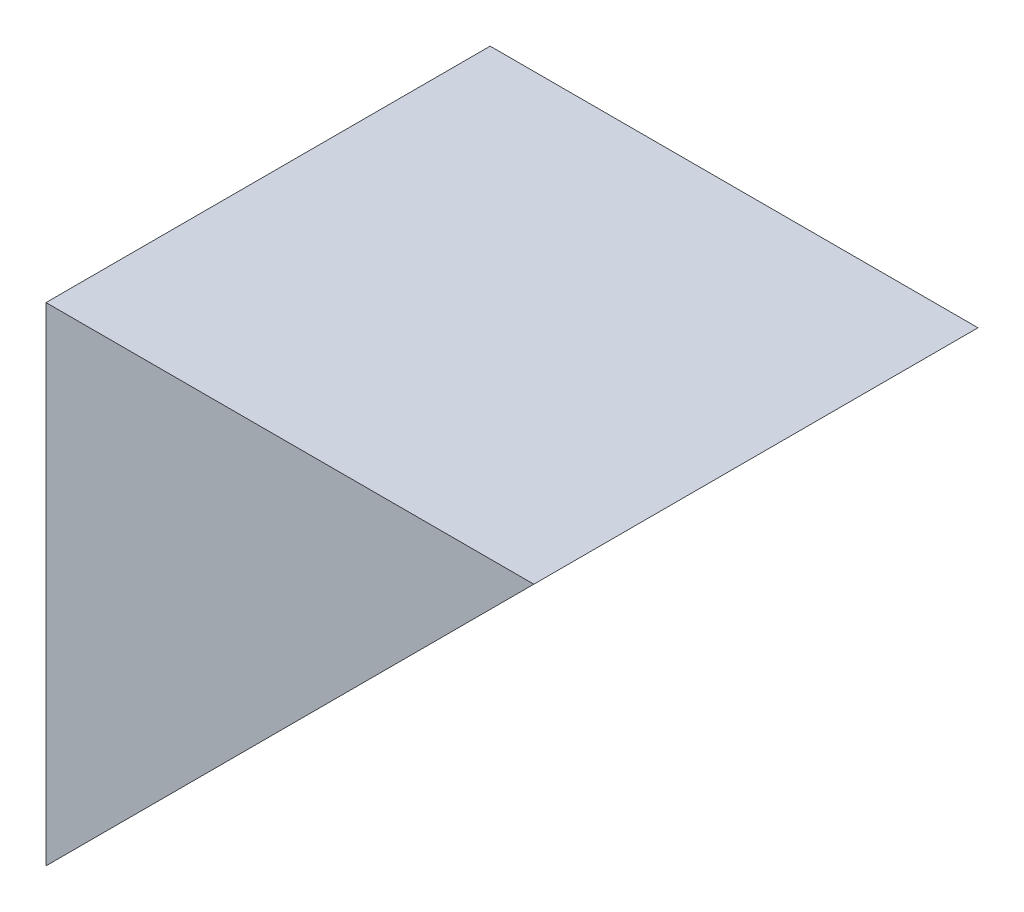
from build123d import *

# Parameters (mm, degrees)
BOSS_EXTRUDE1_DEPTH = 172.974


with BuildPart() as part:
    # Sketch1 → Boss-Extrude1 (new body)
    with BuildSketch(Plane.XY):
        Polygon((0, 0), (189.992, 189.992), (0, 189.992), align=None)
    extrude(amount=BOSS_EXTRUDE1_DEPTH)


solid = part.part
